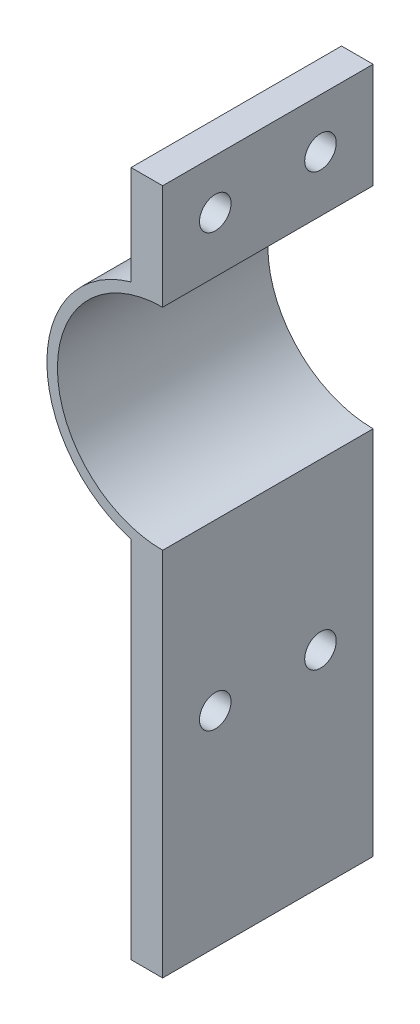
from build123d import *

# Parameters (mm, degrees)
EXTRUDE_1_DEPTH     = 20
SKETCH_2_R          = 1.5
CUT_EXTRUDE_1_DEPTH = 20


with BuildPart() as part:
    # 草图1 → 凸台-拉伸1 (new body)
    with BuildSketch(Plane.XY):
        with BuildLine():
            Line((-3, 20), (-3, 10.583005244))
            ThreePointArc((-3, 10.583005244), (-11, 0), (-3, -10.583005244))
            Line((-3, -10.583005244), (-3, -45.2))
            Line((-3, -45.2), (0, -45.2))
            Line((0, -45.2), (0, -10))
            ThreePointArc((0, -10), (-10, 0), (0, 10))
            Line((0, 10), (0, 20))
            Line((0, 20), (-3, 20))
        make_face()
    extrude(amount=EXTRUDE_1_DEPTH)

    # 草图2 → 切除-拉伸1 (cut)
    with BuildSketch(Plane.ZY.offset(3)):
        with Locations((5, 15.291502622)):
            Circle(SKETCH_2_R)
        with Locations((15, 15.291502622)):
            Circle(SKETCH_2_R)
        with Locations((5, -25.7)):
            Circle(SKETCH_2_R)
        with Locations((15, -25.7)):
            Circle(SKETCH_2_R)
    extrude(amount=-CUT_EXTRUDE_1_DEPTH, mode=Mode.SUBTRACT)


solid = part.part
